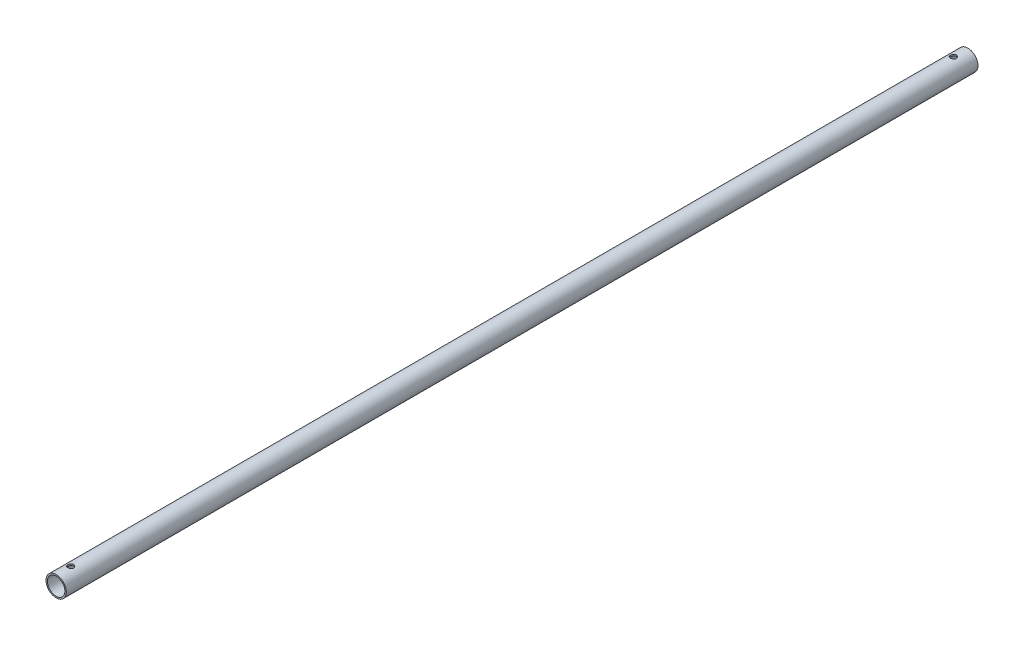
from build123d import *

# Parameters (mm, degrees)
ESQUISSE1_R                  = 3.5
ESQUISSE1_R_2                = 3
BOSS_EXTRU_1_DEPTH           = 314
ENL_V_MAT_EXTRU_1_DEPTH      = 10
ENL_V_MAT_EXTRU_1_DEPTH_BACK = 10
ESQUISSE2_R                  = 1


with BuildPart() as part:
    # Esquisse1 → Boss.-Extru.1 (new body)
    with BuildSketch(Plane.XY):
        Circle(ESQUISSE1_R)
        Circle(ESQUISSE1_R_2, mode=Mode.SUBTRACT)
    extrude(amount=BOSS_EXTRU_1_DEPTH)

    # Esquisse2 → Enlèv. mat.-Extru.1 (cut, two sides: drawn at the far end of the back side and taken through both)
    with BuildSketch(Plane(origin=(0, 0, 0), x_dir=(1, 0, 0), z_dir=(0, 1, 0)).offset(-ENL_V_MAT_EXTRU_1_DEPTH_BACK)):
        with Locations((0, -309)):
            Circle(ESQUISSE2_R)
        with Locations((0, -5)):
            Circle(ESQUISSE2_R)
    extrude(amount=ENL_V_MAT_EXTRU_1_DEPTH + ENL_V_MAT_EXTRU_1_DEPTH_BACK, mode=Mode.SUBTRACT)


solid = part.part
